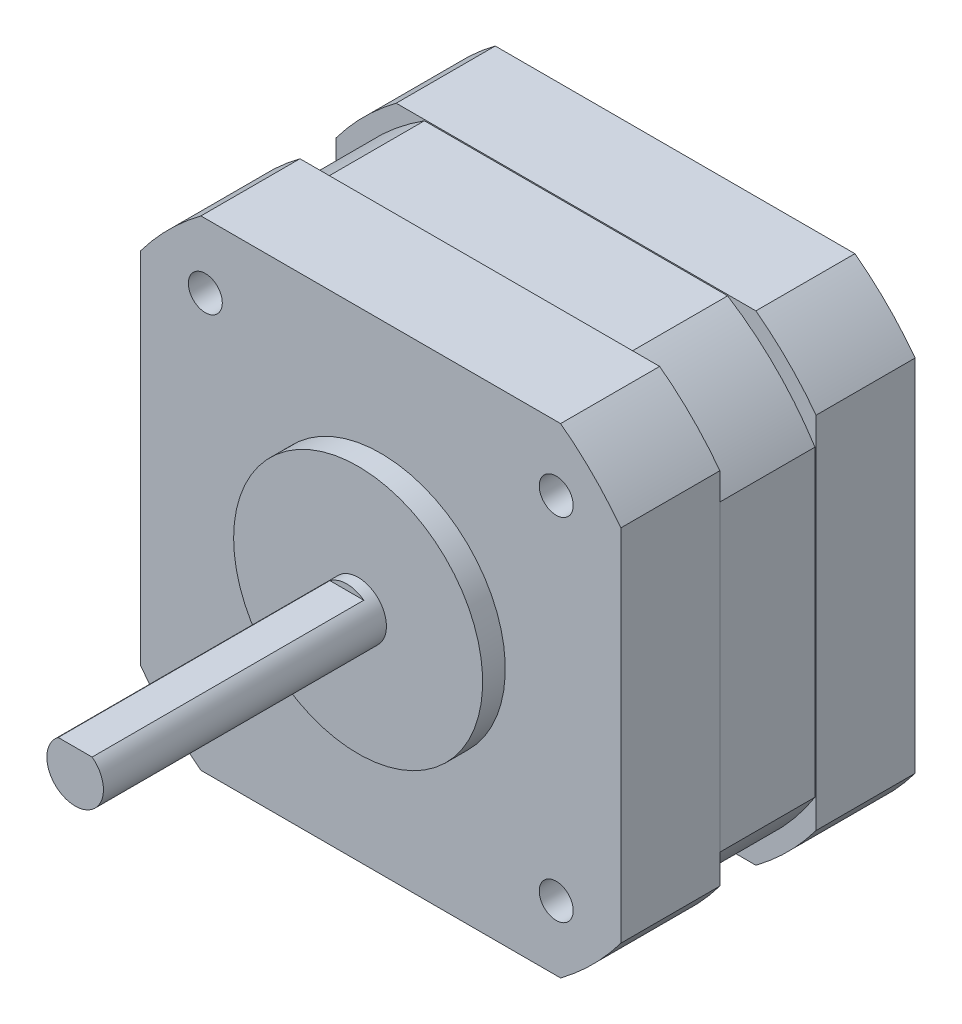
from build123d import *

# Parameters (mm, degrees)
SKETCH1_R                       = 2.5
BOSS_EXTRUDE1_DEPTH             = 27
SKETCH2_R                       = 11
BOSS_EXTRUDE2_DEPTH             = 2
SKETCH3_W                       = 42.418
SKETCH3_H                       = 42.418
BOSS_EXTRUDE3_DEPTH             = 26
CUT_EXTRUDE1_DEPTH              = 54
M3X0_5_TAPPED_HOLE1_D           = 2.5
M3X0_5_TAPPED_HOLE1_DEPTH       = 7.5
M3X0_5_TAPPED_HOLE1_CBORE_D     = 3
M3X0_5_TAPPED_HOLE1_CBORE_DEPTH = 6
M3X0_5_TAPPED_HOLE1_TIP         = 0.751075774
CUT_EXTRUDE2_DEPTH              = 24
CUT_EXTRUDE3_DEPTH              = 4.25
CUT_EXTRUDE3_DEPTH_BACK         = 4.25


with BuildPart() as part:
    # Sketch1 → Boss-Extrude1 (new body)
    with BuildSketch(Plane.XY):
        Circle(SKETCH1_R)
    extrude(amount=BOSS_EXTRUDE1_DEPTH)

    # Sketch2 → Boss-Extrude2 (add)
    with BuildSketch(Plane(origin=(0, 0, 0), x_dir=(-1, 0, 0), z_dir=(0, 0, -1))):
        Circle(SKETCH2_R)
    extrude(amount=-BOSS_EXTRUDE2_DEPTH)

    # Sketch3 → Boss-Extrude3 (add)
    with BuildSketch(Plane(origin=(0, 0, 0), x_dir=(-1, 0, 0), z_dir=(0, 0, -1))):
        Rectangle(SKETCH3_W, SKETCH3_H)
    extrude(amount=BOSS_EXTRUDE3_DEPTH)

    # Sketch4 → Cut-Extrude1 (cut, through all)
    with BuildSketch(Plane(origin=(0, 0, -26), x_dir=(-1, 0, 0), z_dir=(0, 0, -1))):
        with BuildLine():
            Line((-21.209, -15.887992919), (-21.209, -21.209))
            Line((-21.209, -21.209), (-15.887992919, -21.209))
            ThreePointArc((-15.887992919, -21.209), (-18.738329701, -18.738329701), (-21.209, -15.887992919))
        make_face()
        with BuildLine():
            Line((15.887992919, -21.209), (21.209, -21.209))
            Line((21.209, -21.209), (21.209, -15.887992919))
            ThreePointArc((21.209, -15.887992919), (18.738329701, -18.738329701), (15.887992919, -21.209))
        make_face()
        with BuildLine():
            Line((21.209, 15.887992919), (21.209, 21.209))
            Line((21.209, 21.209), (15.887992919, 21.209))
            ThreePointArc((15.887992919, 21.209), (18.738329701, 18.738329701), (21.209, 15.887992919))
        make_face()
        with BuildLine():
            Line((-15.887992919, 21.209), (-21.209, 21.209))
            Line((-21.209, 21.209), (-21.209, 15.887992919))
            ThreePointArc((-21.209, 15.887992919), (-18.738329701, 18.738329701), (-15.887992919, 21.209))
        make_face()
    extrude(amount=-CUT_EXTRUDE1_DEPTH, mode=Mode.SUBTRACT)

    # M3x0.5 Tapped Hole1
    with Locations(Plane.XY):
        with Locations((-15.5, 15.5), (-15.5, -15.5), (15.5, -15.5), (15.5, 15.5)):
            CounterBoreHole(M3X0_5_TAPPED_HOLE1_D / 2, M3X0_5_TAPPED_HOLE1_CBORE_D / 2, M3X0_5_TAPPED_HOLE1_CBORE_DEPTH, depth=M3X0_5_TAPPED_HOLE1_DEPTH)
            with Locations((0, 0, -(M3X0_5_TAPPED_HOLE1_DEPTH + M3X0_5_TAPPED_HOLE1_TIP / 2))):  # 118° drill point
                Cone(0, M3X0_5_TAPPED_HOLE1_D / 2, M3X0_5_TAPPED_HOLE1_TIP, mode=Mode.SUBTRACT)

    # Sketch7 → Cut-Extrude2 (cut)
    with BuildSketch(Plane.XY.offset(27)):
        with BuildLine():
            Line((-1.5, 2), (1.5, 2))
            ThreePointArc((1.5, 2), (0, 2.5), (-1.5, 2))
        make_face()
    extrude(amount=-CUT_EXTRUDE2_DEPTH, mode=Mode.SUBTRACT)

    # Sketch8 → Cut-Extrude3 (cut, two sides)
    with BuildSketch(Plane.XY.offset(-13)) as cut_extrude3_sk:
        with BuildLine():
            Line((15.887992919, 21.209), (-15.887992919, 21.209))
            ThreePointArc((-15.887992919, 21.209), (-18.738329701, 18.738329701), (-21.209, 15.887992919))
            Line((-21.209, 15.887992919), (-21.209, -15.887992919))
            ThreePointArc((-21.209, -15.887992919), (-18.738329701, -18.738329701), (-15.887992919, -21.209))
            Line((-15.887992919, -21.209), (15.887992919, -21.209))
            ThreePointArc((15.887992919, -21.209), (18.738329701, -18.738329701), (21.209, -15.887992919))
            Line((21.209, -15.887992919), (21.209, 15.887992919))
            ThreePointArc((21.209, 15.887992919), (18.738329701, 18.738329701), (15.887992919, 21.209))
        make_face()
        with BuildLine():
            Line((-13.394406258, 21.109), (13.394406258, 21.109))
            ThreePointArc((13.394406258, 21.109), (17.67766953, 17.67766953), (21.109, 13.394406258))
            Line((21.109, 13.394406258), (21.109, -13.394406258))
            ThreePointArc((21.109, -13.394406258), (17.67766953, -17.67766953), (13.394406258, -21.109))
            Line((13.394406258, -21.109), (-13.394406258, -21.109))
            ThreePointArc((-13.394406258, -21.109), (-17.67766953, -17.67766953), (-21.109, -13.394406258))
            Line((-21.109, -13.394406258), (-21.109, 13.394406258))
            ThreePointArc((-21.109, 13.394406258), (-17.67766953, 17.67766953), (-13.394406258, 21.109))
        make_face(mode=Mode.SUBTRACT)
    extrude(amount=CUT_EXTRUDE3_DEPTH, mode=Mode.SUBTRACT)
    extrude(cut_extrude3_sk.sketch, amount=-CUT_EXTRUDE3_DEPTH_BACK, mode=Mode.SUBTRACT)


solid = part.part
